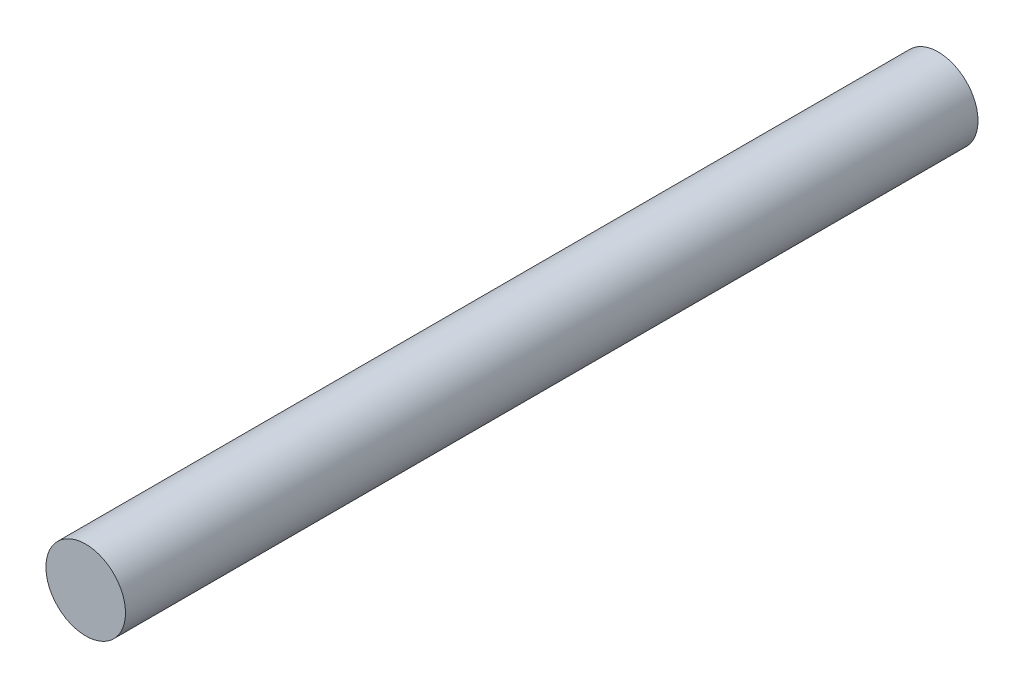
from build123d import *

# Parameters (mm, degrees)
SKETCH1_R           = 3.5
BOSS_EXTRUDE1_DEPTH = 75


with BuildPart() as part:
    # Sketch1 → Boss-Extrude1 (new body)
    with BuildSketch(Plane.XY):
        Circle(SKETCH1_R)
    extrude(amount=BOSS_EXTRUDE1_DEPTH)


solid = part.part
